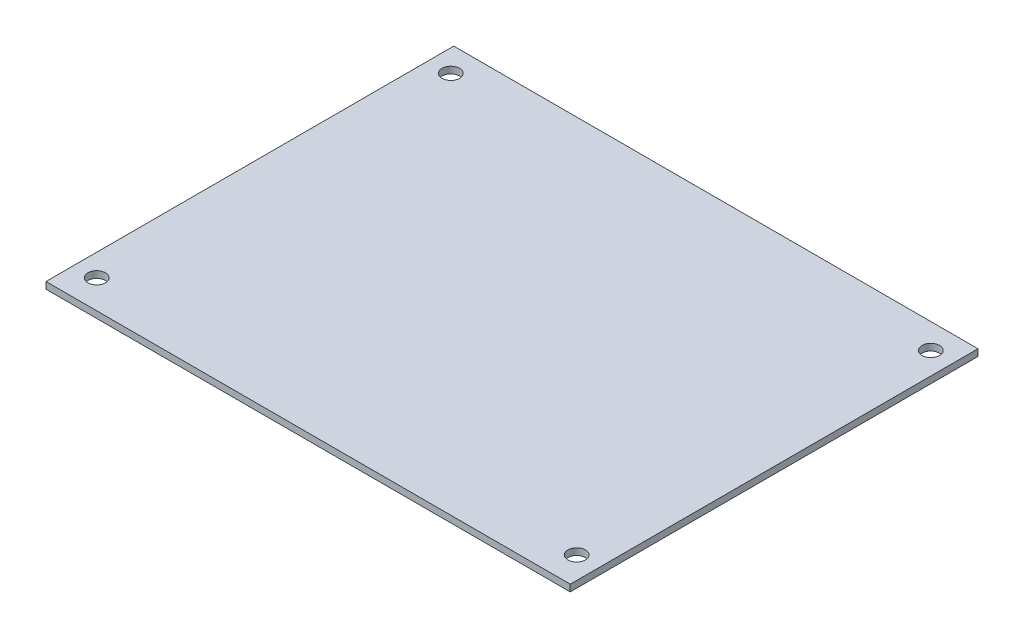
from build123d import *

# Parameters (mm, degrees)
SKETCH_1_W          = 90
SKETCH_1_H          = 70
EXTRUDE_1_DEPTH     = 1.15
SKETCH_2_R          = 1.5
CUT_EXTRUDE_1_DEPTH = 2.15


with BuildPart() as part:
    # 草圖1 → 填料-伸長1 (new body)
    with BuildSketch(Plane(origin=(0, 0, 0), x_dir=(1, 0, 0), z_dir=(0, 1, 0))):
        Rectangle(SKETCH_1_W, SKETCH_1_H)
    extrude(amount=EXTRUDE_1_DEPTH)

    # 草圖2 → 除料-伸長1 (cut, through all)
    with BuildSketch(Plane(origin=(0, 1.15, 0), x_dir=(1, 0, 0), z_dir=(0, 1, 0))):
        with Locations((41.2, 30.7)):
            Circle(SKETCH_2_R)
        with Locations((41.2, -30.1)):
            Circle(SKETCH_2_R)
        with Locations((-41.2, -30.1)):
            Circle(SKETCH_2_R)
        with Locations((-41.2, 30.7)):
            Circle(SKETCH_2_R)
    extrude(amount=-CUT_EXTRUDE_1_DEPTH, mode=Mode.SUBTRACT)


solid = part.part
